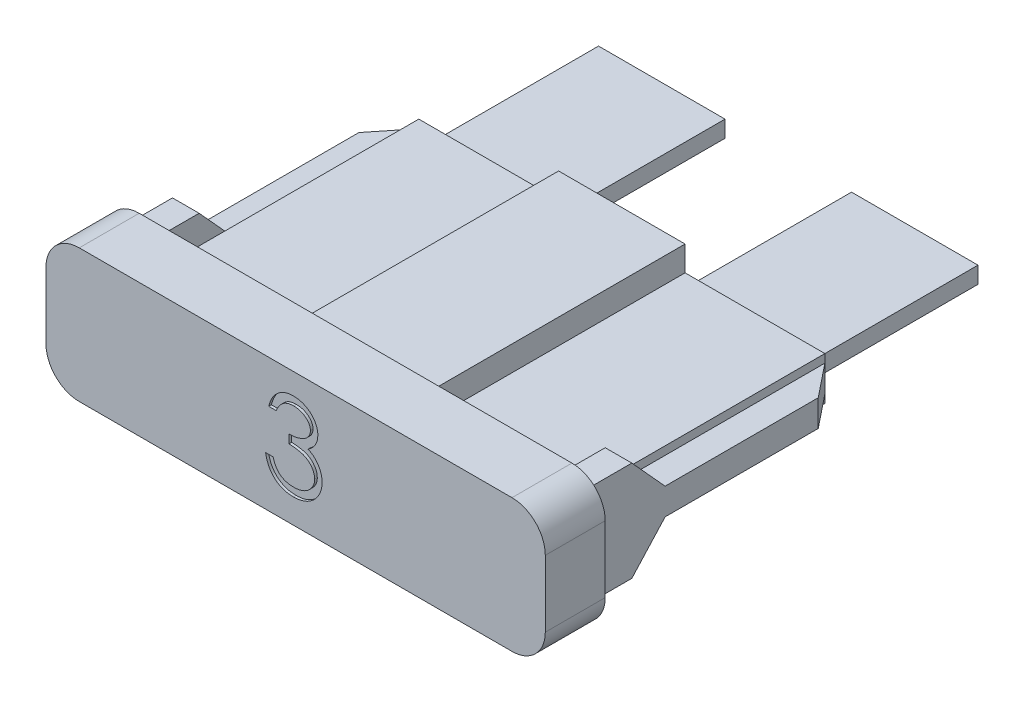
from build123d import *

# Parameters (mm, degrees)
EXTRUDE1_DEPTH      = 2.286
EXTRUDE2_DEPTH      = 10.16
EXTRUDE3_DEPTH      = 1.016
EXTRUDE4_DEPTH      = 1.016
CHAMFER1_SIZE       = 1.016
CHAMFER1_SIZE2      = 1.27
BLADE_DEPTH         = 0.635
CUT_EXTRUDE_3_DEPTH = 0.1016


with BuildPart() as part:
    # Sketch1 → Extrude1 (new body)
    with BuildSketch(Plane.XY):
        with BuildLine():
            Line((1.27, 0), (17.78, 0))
            ThreePointArc((17.78, 0), (18.678025612, 0.371974388), (19.05, 1.27))
            Line((19.05, 1.27), (19.05, 3.81))
            ThreePointArc((19.05, 3.81), (18.678025612, 4.708025612), (17.78, 5.08))
            Line((17.78, 5.08), (1.27, 5.08))
            ThreePointArc((1.27, 5.08), (0.371974388, 4.708025612), (0, 3.81))
            Line((0, 3.81), (0, 1.27))
            ThreePointArc((0, 1.27), (0.371974388, 0.371974388), (1.27, 0))
        make_face()
    extrude(amount=EXTRUDE1_DEPTH)

    # Sketch2 → Extrude2 (add)
    with BuildSketch(Plane(origin=(0, 0, 0), x_dir=(-1, 0, 0), z_dir=(0, 0, -1))):
        Polygon((-11.938, 4.318), (-11.938, 3.3655), (-17.272, 3.3655), (-17.272, 1.7145), (-11.938, 1.7145), (-11.938, 0.762), (-7.112, 0.762), (-7.112, 1.7145), (-1.778, 1.7145), (-1.778, 3.3655), (-7.112, 3.3655), (-7.112, 4.318), align=None)
        Polygon((-7.62, 2.2225), (-7.62, 1.27), (-11.43, 1.27), (-11.43, 2.2225), (-16.764, 2.2225), (-16.764, 2.8575), (-11.43, 2.8575), (-11.43, 3.81), (-7.62, 3.81), (-7.62, 2.8575), (-2.286, 2.8575), (-2.286, 2.2225), align=None, mode=Mode.SUBTRACT)
    extrude(amount=EXTRUDE2_DEPTH)

    # Sketch3 → Extrude3 (add)
    with BuildSketch(Plane.ZY.offset(-1.778)):
        Polygon((-10.16, 3.048), (-3.048, 3.048), (-1.778, 4.445), (0, 4.445), (0, 0.635), (-1.778, 0.635), (-3.048, 2.032), (-10.16, 2.032), align=None)
    extrude(amount=EXTRUDE3_DEPTH)

    # Sketch4 → Extrude4 (add)
    with BuildSketch(Plane(origin=(17.272, 0, 0), x_dir=(0, 0, -1), z_dir=(1, 0, 0))):
        Polygon((3.048, 3.048), (10.16, 3.048), (10.16, 2.032), (3.048, 2.032), (1.778, 0.635), (0, 0.635), (0, 4.445), (1.778, 4.445), align=None)
    extrude(amount=EXTRUDE4_DEPTH)

    # Chamfer1
    chamfer1_edges = [part.edges().sort_by_distance(p)[0] for p in [
        (0.762, 2.54, -10.16),
        (18.288, 2.54, -10.16),
    ]]
    chamfer1_side = [part.faces().sort_by_distance(p)[0] for p in [
        (11.759168847, 3.84175, -10.16),
    ]]
    chamfer(chamfer1_edges, length=CHAMFER1_SIZE, length2=CHAMFER1_SIZE2, reference=chamfer1_side[0])

    # Sketch8 → Blade (add)
    with BuildSketch(Plane(origin=(0, 2.2225, 0), x_dir=(-1, 0, 0), z_dir=(0, 1, 0))):
        with BuildLine():
            Line((-2.286, 0), (-7.112, 0))
            Line((-7.112, 0), (-7.112, -6.858))
            Line((-7.112, -6.858), (-7.366, -6.858))
            ThreePointArc((-7.366, -6.858), (-7.815012806, -6.672012806), (-8.001, -6.223))
            Line((-8.001, -6.223), (-8.001, -3.175))
            ThreePointArc((-8.001, -3.175), (-8.410171827, -2.187171827), (-9.398, -1.778))
            Line((-9.398, -1.778), (-9.652, -1.778))
            ThreePointArc((-9.652, -1.778), (-10.639828173, -2.187171827), (-11.049, -3.175))
            Line((-11.049, -3.175), (-11.049, -6.223))
            ThreePointArc((-11.049, -6.223), (-11.234987194, -6.672012806), (-11.684, -6.858))
            Line((-11.684, -6.858), (-11.938, -6.858))
            Line((-11.938, -6.858), (-11.938, 0))
            Line((-11.938, 0), (-16.764, 0))
            Line((-16.764, 0), (-16.764, -16.51))
            Line((-16.764, -16.51), (-11.938, -16.51))
            Line((-11.938, -16.51), (-11.938, -7.62))
            Line((-11.938, -7.62), (-10.922, -7.62))
            ThreePointArc((-10.922, -7.62), (-10.472987194, -7.434012806), (-10.287, -6.985))
            Line((-10.287, -6.985), (-10.287, -3.175))
            ThreePointArc((-10.287, -3.175), (-10.101012806, -2.725987194), (-9.652, -2.54))
            Line((-9.652, -2.54), (-9.398, -2.54))
            ThreePointArc((-9.398, -2.54), (-8.948987194, -2.725987194), (-8.763, -3.175))
            Line((-8.763, -3.175), (-8.763, -6.985))
            ThreePointArc((-8.763, -6.985), (-8.577012806, -7.434012806), (-8.128, -7.62))
            Line((-8.128, -7.62), (-7.112, -7.62))
            Line((-7.112, -7.62), (-7.112, -16.51))
            Line((-7.112, -16.51), (-2.286, -16.51))
            Line((-2.286, -16.51), (-2.286, 0))
        make_face()
    extrude(amount=BLADE_DEPTH)

    # Sketch15 → "3" (cut)
    with BuildSketch(Plane.XY.offset(2.286)):
        with BuildLine():
            Line((8.784166667, 3.458307692), (8.499230769, 3.458307692))
            add(Edge.make_bspline(
                [(8.499230769, 3.458307692), (8.506950147, 3.490268588), (8.5220409, 3.552749526), (8.553516556, 3.64201897), (8.58780588, 3.726495307), (8.628980282, 3.804596746), (8.673891795, 3.877892893), (8.725347407, 3.944721313), (8.780973155, 4.006781646), (8.842500074, 4.061857226), (8.907023931, 4.11172988), (8.975453907, 4.154252254), (9.046413247, 4.190832021), (9.120393589, 4.220967517), (9.197615187, 4.243669242), (9.277379917, 4.260140059), (9.359896806, 4.270836284), (9.415910692, 4.27188019), (9.444352965, 4.272410256)],
                knots=[0, 0, 0, 0, 9.8575e-05, 0.000192705, 0.000283656, 0.000371842, 0.000457261, 0.000541217, 0.000624516, 0.000706917, 0.000788585, 0.000868879, 0.000948242, 0.001027846, 0.001108138, 0.001189341, 0.001272016, 0.001357302, 0.001357302, 0.001357302, 0.001357302], degree=3))
            add(Edge.make_bspline(
                [(9.444352965, 4.272410256), (9.485793738, 4.271159098), (9.567771341, 4.268684071), (9.68820639, 4.246083118), (9.804345005, 4.210318891), (9.914915965, 4.160903438), (10.017621258, 4.099954947), (10.10900337, 4.027415507), (10.187823662, 3.944684712), (10.253949276, 3.853305886), (10.305724454, 3.75564696), (10.343902807, 3.655135389), (10.367145332, 3.5520096), (10.370157551, 3.482379783), (10.371666667, 3.447495393)],
                knots=[0, 0, 0, 0, 0.000124221, 0.000245732, 0.000366235, 0.000488093, 0.000608186, 0.000723607, 0.000836972, 0.000949947, 0.001060913, 0.001167586, 0.001271755, 0.001376341, 0.001376341, 0.001376341, 0.001376341], degree=3))
            add(Edge.make_bspline(
                [(10.371666667, 3.447495393), (10.370611123, 3.413924943), (10.368545589, 3.348232783), (10.351007156, 3.252328282), (10.321492118, 3.161939116), (10.280607404, 3.076684776), (10.227683284, 2.997105814), (10.163573052, 2.923023185), (10.087824208, 2.854108306), (10.030421172, 2.814629927), (10.000868389, 2.794305288)],
                knots=[0, 0, 0, 0, 0.000100654, 0.000196964, 0.000291294, 0.000385168, 0.000479719, 0.000577128, 0.000678438, 0.000785942, 0.000785942, 0.000785942, 0.000785942], degree=3))
            add(Edge.make_bspline(
                [(10.000868389, 2.794305288), (10.03464291, 2.777996519), (10.101560003, 2.745684128), (10.192773697, 2.682314977), (10.27557577, 2.609148148), (10.321752715, 2.55205017), (10.344953926, 2.523361779)],
                knots=[0, 0, 0, 0, 0.000112361, 0.00022262, 0.000332061, 0.000442576, 0.000442576, 0.000442576, 0.000442576], degree=3))
            add(Edge.make_bspline(
                [(10.344953926, 2.523361779), (10.36023143, 2.502445104), (10.390536257, 2.46095428), (10.427942777, 2.394246236), (10.461878188, 2.326798814), (10.488321601, 2.25680421), (10.508799323, 2.18507369), (10.523437009, 2.111484088), (10.532530337, 2.035975311), (10.533832588, 1.984891847), (10.534487179, 1.959214143)],
                knots=[0, 0, 0, 0, 7.7636e-05, 0.000154, 0.000229094, 0.000303982, 0.000378066, 0.000452657, 0.000528865, 0.000605889, 0.000605889, 0.000605889, 0.000605889], degree=3))
            add(Edge.make_bspline(
                [(10.534487179, 1.959214143), (10.532859299, 1.914755324), (10.5296112, 1.826046911), (10.500578933, 1.694987699), (10.455572636, 1.566875994), (10.391658129, 1.444343818), (10.313764032, 1.329698758), (10.221092745, 1.227122392), (10.114697218, 1.138949372), (9.996037808, 1.065280094), (9.867480127, 1.006390265), (9.729979411, 0.965516727), (9.585516862, 0.938895713), (9.486450242, 0.936041054), (9.436084736, 0.934589744)],
                knots=[0, 0, 0, 0, 0.000133226, 0.000265824, 0.000400805, 0.00053962, 0.000679164, 0.000815599, 0.000952897, 0.001092317, 0.00123349, 0.001375737, 0.001521711, 0.001672674, 0.001672674, 0.001672674, 0.001672674], degree=3))
            add(Edge.make_bspline(
                [(9.436084736, 0.934589744), (9.402140085, 0.935377337), (9.335348331, 0.936927058), (9.237156014, 0.947521218), (9.143428473, 0.96687058), (9.05403898, 0.992908578), (8.968908126, 1.025921087), (8.888295688, 1.06703162), (8.811705713, 1.115392769), (8.73986095, 1.171575381), (8.672769964, 1.234423453), (8.612215707, 1.305052698), (8.557188609, 1.382157486), (8.509162072, 1.466633401), (8.465948551, 1.557388741), (8.430405826, 1.655585593), (8.399122489, 1.760346099), (8.384577846, 1.833350906), (8.377115385, 1.870807692)],
                knots=[0, 0, 0, 0, 0.000101834, 0.000200376, 0.000295798, 0.00038858, 0.000479406, 0.000569289, 0.000659631, 0.000750724, 0.000842509, 0.00093495, 0.001029366, 0.001126242, 0.001226104, 0.001330545, 0.001439228, 0.001553746, 0.001553746, 0.001553746, 0.001553746], degree=3))
            Line((8.377115385, 1.870807692), (8.662051282, 1.870807692))
            add(Edge.make_bspline(
                [(8.662051282, 1.870807692), (8.669474696, 1.846361087), (8.683913882, 1.798810317), (8.708492281, 1.730375183), (8.736494214, 1.667638949), (8.766533849, 1.610141403), (8.798082868, 1.557316295), (8.833384264, 1.510560456), (8.869823417, 1.467820237), (8.897291116, 1.443740482), (8.910734175, 1.431955529)],
                knots=[0, 0, 0, 0, 7.6642e-05, 0.000149076, 0.00021798, 0.000282557, 0.000343641, 0.000402283, 0.000458165, 0.000511731, 0.000511731, 0.000511731, 0.000511731], degree=3))
            add(Edge.make_bspline(
                [(8.910734175, 1.431955529), (8.928511069, 1.418250112), (8.964009985, 1.390881583), (9.02185688, 1.355955106), (9.082694312, 1.32569189), (9.147840481, 1.302574537), (9.215889594, 1.283000516), (9.287941561, 1.270191188), (9.363360708, 1.261402633), (9.41485718, 1.260627088), (9.441172877, 1.260230769)],
                knots=[0, 0, 0, 0, 6.7292e-05, 0.000134376, 0.000202358, 0.000270771, 0.000341449, 0.00041455, 0.000490054, 0.000568961, 0.000568961, 0.000568961, 0.000568961], degree=3))
            add(Edge.make_bspline(
                [(9.441172877, 1.260230769), (9.470884983, 1.260789483), (9.528984441, 1.261882), (9.613761349, 1.271929249), (9.694413105, 1.286561838), (9.770044259, 1.309161472), (9.841645505, 1.337084102), (9.908213144, 1.372143727), (9.970621041, 1.413277867), (10.028069858, 1.460031247), (10.079727569, 1.511213603), (10.12521127, 1.564746889), (10.163877927, 1.620405392), (10.195068745, 1.678497116), (10.219698172, 1.738781502), (10.236465076, 1.801427726), (10.248123236, 1.865923103), (10.249072663, 1.909764382), (10.249551282, 1.931865385)],
                knots=[0, 0, 0, 0, 8.9099e-05, 0.000174226, 0.000255805, 0.000334697, 0.000410639, 0.000486028, 0.00055994, 0.000634539, 0.000707846, 0.0007778, 0.000845016, 0.000910751, 0.000975237, 0.001039889, 0.001105031, 0.001171253, 0.001171253, 0.001171253, 0.001171253], degree=3))
            add(Edge.make_bspline(
                [(10.249551282, 1.931865385), (10.24816308, 1.961448528), (10.245393583, 2.020467612), (10.224249372, 2.107297126), (10.189470545, 2.190956936), (10.14078191, 2.270019688), (10.08151307, 2.343294971), (10.01223919, 2.408674101), (9.932385012, 2.462621969), (9.858888416, 2.499895251), (9.793787167, 2.525328883), (9.73807464, 2.542269744), (9.675702578, 2.556614988), (9.607425248, 2.56996112), (9.532728187, 2.581319772), (9.451692718, 2.590791991), (9.36430242, 2.598371206), (9.303804005, 2.601755843), (9.272628205, 2.6035)],
                knots=[0, 0, 0, 0, 8.8683e-05, 0.000176924, 0.000266456, 0.0003595, 0.00045446, 0.000548507, 0.000644124, 0.00074254, 0.000795099, 0.000853644, 0.000917048, 0.000987025, 0.001062314, 0.00114365, 0.001231751, 0.001325421, 0.001325421, 0.001325421, 0.001325421], degree=3))
            Line((9.272628205, 2.6035), (9.272628205, 2.929141026))
            add(Edge.make_bspline(
                [(9.272628205, 2.929141026), (9.311908548, 2.929807598), (9.388849091, 2.931113248), (9.501238925, 2.946904801), (9.608711144, 2.96874937), (9.708883974, 3.002209509), (9.800186735, 3.041071778), (9.879398089, 3.086294854), (9.945408287, 3.136563948), (9.997896544, 3.192654958), (10.037383773, 3.25281218), (10.066255225, 3.315510862), (10.083309807, 3.381300546), (10.085586433, 3.42619928), (10.086730769, 3.448767428)],
                knots=[0, 0, 0, 0, 0.000117747, 0.000230638, 0.000339915, 0.000446313, 0.000546864, 0.000637192, 0.000719248, 0.000794851, 0.00086647, 0.000934214, 0.001001162, 0.001068823, 0.001068823, 0.001068823, 0.001068823], degree=3))
            add(Edge.make_bspline(
                [(10.086730769, 3.448767428), (10.086354839, 3.465347954), (10.085606944, 3.498334124), (10.076175128, 3.54652615), (10.062001891, 3.593244866), (10.042516708, 3.638291594), (10.016436171, 3.681353913), (9.985225026, 3.722798956), (9.948061106, 3.762390099), (9.905474879, 3.79929296), (9.85974417, 3.834462197), (9.809624732, 3.864319567), (9.756627745, 3.889851159), (9.700694537, 3.910905493), (9.641643592, 3.926743562), (9.579752357, 3.938115361), (9.514902816, 3.945225234), (9.470659887, 3.946248868), (9.448169071, 3.946769231)],
                knots=[0, 0, 0, 0, 4.9675e-05, 9.8825e-05, 0.000146708, 0.000195982, 0.000245612, 0.000297384, 0.000351382, 0.000408162, 0.000466295, 0.000524214, 0.000582814, 0.00064259, 0.000703225, 0.000765972, 0.000831222, 0.000898688, 0.000898688, 0.000898688, 0.000898688], degree=3))
            add(Edge.make_bspline(
                [(9.448169071, 3.946769231), (9.412017915, 3.945507067), (9.341406299, 3.943041767), (9.239611338, 3.921449033), (9.1449788, 3.886997486), (9.072644438, 3.845873961), (9.019229531, 3.805278925), (8.981059737, 3.769825617), (8.943576132, 3.730425841), (8.909244696, 3.684652887), (8.874524732, 3.635606584), (8.842915736, 3.580793673), (8.812200159, 3.521643972), (8.793692131, 3.479828647), (8.784166667, 3.458307692)],
                knots=[0, 0, 0, 0, 0.000108349, 0.000211631, 0.000310638, 0.000409485, 0.000459859, 0.000511627, 0.000565625, 0.000622746, 0.000683084, 0.000745805, 0.000812368, 0.000882955, 0.000882955, 0.000882955, 0.000882955], degree=3))
        make_face()
    extrude(amount=-CUT_EXTRUDE_3_DEPTH, mode=Mode.SUBTRACT)


solid = part.part
